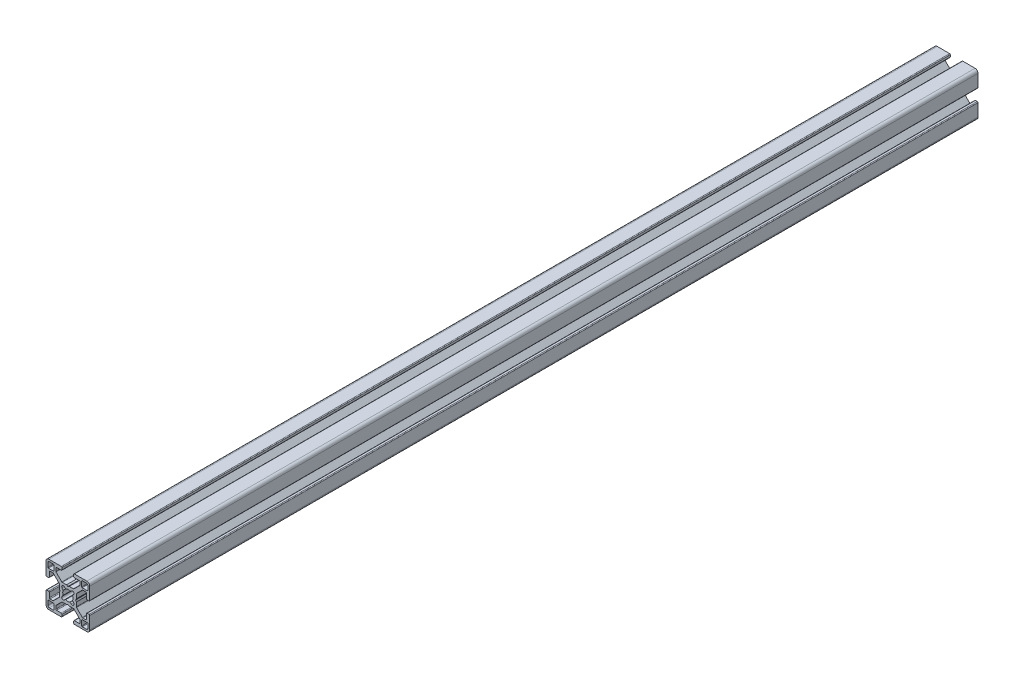
from build123d import *

# Parameters (mm, degrees)
EXTRUDE1_DEPTH = 609.6


with BuildPart() as part:
    # Sketch1 → Extrude1 (new body)
    with BuildSketch(Plane.XY):
        with BuildLine():
            Line((12.74247465, -4.5), (12.74247465, -7.732519321))
            ThreePointArc((12.74247465, -7.732519321), (12.602449697, -8.097296796), (12.242781236, -8.249967))
            Line((12.242781236, -8.249967), (10.260188032, -8.249967))
            ThreePointArc((10.260188032, -8.249967), (10.068847082, -8.211906919), (9.906636056, -8.103520976))
            Line((9.906636056, -8.103520976), (5.981117769, -4.178002689))
            ThreePointArc((5.981117769, -4.178002689), (5.872731827, -4.015791664), (5.834671745, -3.824450713))
            Line((5.834671745, -3.824450713), (5.834671745, -1.01249595))
            Line((5.834671745, -1.01249595), (5.324673785, -0.06249975))
            Line((5.324673785, -0.06249975), (5.834671745, 0.88749645))
            Line((5.834671745, 0.88749645), (5.834671745, 3.824450713))
            ThreePointArc((5.834671745, 3.824450713), (5.872731827, 4.015791664), (5.981117769, 4.178002689))
            Line((5.981117769, 4.178002689), (9.906636056, 8.103520976))
            ThreePointArc((9.906636056, 8.103520976), (10.068847082, 8.211906919), (10.260188032, 8.249967))
            Line((10.260188032, 8.249967), (12.242781236, 8.249967))
            ThreePointArc((12.242781236, 8.249967), (12.602449697, 8.097296796), (12.74247465, 7.732519321))
            Line((12.74247465, 7.732519321), (12.74247465, 4.5))
            ThreePointArc((12.74247465, 4.5), (12.88892126, 4.146446609), (13.24247465, 4))
            Line((13.24247465, 4), (14.49994, 4))
            ThreePointArc((14.49994, 4), (14.853493391, 4.146446609), (14.99994, 4.5))
            Line((14.99994, 4.5), (14.99994, 12.999948))
            ThreePointArc((14.99994, 12.999948), (14.414155906, 14.414155906), (12.999948, 14.99994))
            Line((12.999948, 14.99994), (4.5, 14.99994))
            ThreePointArc((4.5, 14.99994), (4.146446609, 14.853493391), (4, 14.49994))
            Line((4, 14.49994), (4, 13.24247465))
            ThreePointArc((4, 13.24247465), (4.146446609, 12.88892126), (4.5, 12.74247465))
            Line((4.5, 12.74247465), (7.732519321, 12.74247465))
            ThreePointArc((7.732519321, 12.74247465), (8.097296796, 12.602449697), (8.249967, 12.242781236))
            Line((8.249967, 12.242781236), (8.249967, 10.260188032))
            ThreePointArc((8.249967, 10.260188032), (8.211906919, 10.068847082), (8.103520976, 9.906636056))
            Line((8.103520976, 9.906636056), (4.178002689, 5.981117769))
            ThreePointArc((4.178002689, 5.981117769), (4.015791664, 5.872731827), (3.824450713, 5.834671745))
            Line((3.824450713, 5.834671745), (0.9499962, 5.834671745))
            Line((0.9499962, 5.834671745), (0, 5.324673785))
            Line((0, 5.324673785), (-0.9499962, 5.834671745))
            Line((-0.9499962, 5.834671745), (-3.824450713, 5.834671745))
            ThreePointArc((-3.824450713, 5.834671745), (-4.015791664, 5.872731827), (-4.178002689, 5.981117769))
            Line((-4.178002689, 5.981117769), (-8.103520976, 9.906636056))
            ThreePointArc((-8.103520976, 9.906636056), (-8.211906919, 10.068847082), (-8.249967, 10.260188032))
            Line((-8.249967, 10.260188032), (-8.249967, 12.242781236))
            ThreePointArc((-8.249967, 12.242781236), (-8.097296796, 12.602449697), (-7.732519321, 12.74247465))
            Line((-7.732519321, 12.74247465), (-4.5, 12.74247465))
            ThreePointArc((-4.5, 12.74247465), (-4.146446609, 12.88892126), (-4, 13.24247465))
            Line((-4, 13.24247465), (-4, 14.49994))
            ThreePointArc((-4, 14.49994), (-4.146446609, 14.853493391), (-4.5, 14.99994))
            Line((-4.5, 14.99994), (-12.999948, 14.99994))
            ThreePointArc((-12.999948, 14.99994), (-14.414155906, 14.414155906), (-14.99994, 12.999948))
            Line((-14.99994, 12.999948), (-14.99994, 4.5))
            ThreePointArc((-14.99994, 4.5), (-14.853493391, 4.146446609), (-14.49994, 4))
            Line((-14.49994, 4), (-13.24247465, 4))
            ThreePointArc((-13.24247465, 4), (-12.88892126, 4.146446609), (-12.74247465, 4.5))
            Line((-12.74247465, 4.5), (-12.74247465, 7.732519321))
            ThreePointArc((-12.74247465, 7.732519321), (-12.602449697, 8.097296796), (-12.242781236, 8.249967))
            Line((-12.242781236, 8.249967), (-10.260188032, 8.249967))
            ThreePointArc((-10.260188032, 8.249967), (-10.068847082, 8.211906919), (-9.906636056, 8.103520976))
            Line((-9.906636056, 8.103520976), (-5.981117769, 4.178002689))
            ThreePointArc((-5.981117769, 4.178002689), (-5.872731827, 4.015791664), (-5.834671745, 3.824450713))
            Line((-5.834671745, 3.824450713), (-5.834671745, 0.88749645))
            Line((-5.834671745, 0.88749645), (-5.324673785, -0.06249975))
            Line((-5.324673785, -0.06249975), (-5.834671745, -1.01249595))
            Line((-5.834671745, -1.01249595), (-5.834671745, -3.824450713))
            ThreePointArc((-5.834671745, -3.824450713), (-5.872731827, -4.015791664), (-5.981117769, -4.178002689))
            Line((-5.981117769, -4.178002689), (-9.906636056, -8.103520976))
            ThreePointArc((-9.906636056, -8.103520976), (-10.068847082, -8.211906919), (-10.260188032, -8.249967))
            Line((-10.260188032, -8.249967), (-12.242781236, -8.249967))
            ThreePointArc((-12.242781236, -8.249967), (-12.602449697, -8.097296796), (-12.74247465, -7.732519321))
            Line((-12.74247465, -7.732519321), (-12.74247465, -4.5))
            ThreePointArc((-12.74247465, -4.5), (-12.88892126, -4.146446609), (-13.24247465, -4))
            Line((-13.24247465, -4), (-14.49994, -4))
            ThreePointArc((-14.49994, -4), (-14.853493391, -4.146446609), (-14.99994, -4.5))
            Line((-14.99994, -4.5), (-14.99994, -12.999948))
            ThreePointArc((-14.99994, -12.999948), (-14.414155906, -14.414155906), (-12.999948, -14.99994))
            Line((-12.999948, -14.99994), (-4.5, -14.99994))
            ThreePointArc((-4.5, -14.99994), (-4.146446609, -14.853493391), (-4, -14.49994))
            Line((-4, -14.49994), (-4, -13.24247465))
            ThreePointArc((-4, -13.24247465), (-4.146446609, -12.88892126), (-4.5, -12.74247465))
            Line((-4.5, -12.74247465), (-7.732519321, -12.74247465))
            ThreePointArc((-7.732519321, -12.74247465), (-8.097296796, -12.602449697), (-8.249967, -12.242781236))
            Line((-8.249967, -12.242781236), (-8.249967, -10.260188032))
            ThreePointArc((-8.249967, -10.260188032), (-8.211906919, -10.068847082), (-8.103520976, -9.906636056))
            Line((-8.103520976, -9.906636056), (-4.178002689, -5.981117769))
            ThreePointArc((-4.178002689, -5.981117769), (-4.015791664, -5.872731827), (-3.824450713, -5.834671745))
            Line((-3.824450713, -5.834671745), (-0.9499962, -5.834671745))
            Line((-0.9499962, -5.834671745), (0, -5.324673785))
            Line((0, -5.324673785), (0.9499962, -5.834671745))
            Line((0.9499962, -5.834671745), (3.824450713, -5.834671745))
            ThreePointArc((3.824450713, -5.834671745), (4.015791664, -5.872731827), (4.178002689, -5.981117769))
            Line((4.178002689, -5.981117769), (8.103520976, -9.906636056))
            ThreePointArc((8.103520976, -9.906636056), (8.211906919, -10.068847082), (8.249967, -10.260188032))
            Line((8.249967, -10.260188032), (8.249967, -12.242781236))
            ThreePointArc((8.249967, -12.242781236), (8.097296796, -12.602449697), (7.732519321, -12.74247465))
            Line((7.732519321, -12.74247465), (4.5, -12.74247465))
            ThreePointArc((4.5, -12.74247465), (4.146446609, -12.88892126), (4, -13.24247465))
            Line((4, -13.24247465), (4, -14.49994))
            ThreePointArc((4, -14.49994), (4.146446609, -14.853493391), (4.5, -14.99994))
            Line((4.5, -14.99994), (12.999948, -14.99994))
            ThreePointArc((12.999948, -14.99994), (14.414155906, -14.414155906), (14.99994, -12.999948))
            Line((14.99994, -12.999948), (14.99994, -4.5))
            ThreePointArc((14.99994, -4.5), (14.853493391, -4.146446609), (14.49994, -4))
            Line((14.49994, -4), (13.24247465, -4))
            ThreePointArc((13.24247465, -4), (12.88892126, -4.146446609), (12.74247465, -4.5))
        make_face()
        with BuildLine():
            Line((9.499962, -13.318946724), (9.499962, -9.87996048))
            ThreePointArc((9.499962, -9.87996048), (9.611260978, -9.611260978), (9.87996048, -9.499962))
            Line((9.87996048, -9.499962), (13.318946724, -9.499962))
            ThreePointArc((13.318946724, -9.499962), (13.58835333, -9.61155387), (13.6999452, -9.880960476))
            Line((13.6999452, -9.880960476), (13.6999452, -12.6999492))
            ThreePointArc((13.6999452, -12.6999492), (13.407053153, -13.407053153), (12.6999492, -13.6999452))
            Line((12.6999492, -13.6999452), (9.880960476, -13.6999452))
            ThreePointArc((9.880960476, -13.6999452), (9.61155387, -13.58835333), (9.499962, -13.318946724))
        make_face(mode=Mode.SUBTRACT)
        with BuildLine():
            Line((-13.318946724, -9.499962), (-9.87996048, -9.499962))
            ThreePointArc((-9.87996048, -9.499962), (-9.611260978, -9.611260978), (-9.499962, -9.87996048))
            Line((-9.499962, -9.87996048), (-9.499962, -13.318946724))
            ThreePointArc((-9.499962, -13.318946724), (-9.61155387, -13.58835333), (-9.880960476, -13.6999452))
            Line((-9.880960476, -13.6999452), (-12.6999492, -13.6999452))
            ThreePointArc((-12.6999492, -13.6999452), (-13.407053153, -13.407053153), (-13.6999452, -12.6999492))
            Line((-13.6999452, -12.6999492), (-13.6999452, -9.880960476))
            ThreePointArc((-13.6999452, -9.880960476), (-13.58835333, -9.61155387), (-13.318946724, -9.499962))
        make_face(mode=Mode.SUBTRACT)
        with BuildLine():
            Line((-1.494225248, -3.198138712), (-2.473341823, -3.979927146))
            ThreePointArc((-2.473341823, -3.979927146), (-3.900227701, -3.900227701), (-3.979927146, -2.473341823))
            Line((-3.979927146, -2.473341823), (-3.198138712, -1.494225248))
            ThreePointArc((-3.198138712, -1.494225248), (-3.52998588, 0), (-3.198138712, 1.494225248))
            Line((-3.198138712, 1.494225248), (-3.979927146, 2.473341823))
            ThreePointArc((-3.979927146, 2.473341823), (-3.900227701, 3.900227701), (-2.473341823, 3.979927146))
            Line((-2.473341823, 3.979927146), (-1.494225248, 3.198138712))
            ThreePointArc((-1.494225248, 3.198138712), (0, 3.52998588), (1.494225248, 3.198138712))
            Line((1.494225248, 3.198138712), (2.473341823, 3.979927146))
            ThreePointArc((2.473341823, 3.979927146), (3.900227701, 3.900227701), (3.979927146, 2.473341823))
            Line((3.979927146, 2.473341823), (3.198138712, 1.494225248))
            ThreePointArc((3.198138712, 1.494225248), (3.52998588, 0), (3.198138712, -1.494225248))
            Line((3.198138712, -1.494225248), (3.979927146, -2.473341823))
            ThreePointArc((3.979927146, -2.473341823), (3.900227701, -3.900227701), (2.473341823, -3.979927146))
            Line((2.473341823, -3.979927146), (1.494225248, -3.198138712))
            ThreePointArc((1.494225248, -3.198138712), (0, -3.52998588), (-1.494225248, -3.198138712))
        make_face(mode=Mode.SUBTRACT)
        with BuildLine():
            Line((-9.499962, 13.318946724), (-9.499962, 9.87996048))
            ThreePointArc((-9.499962, 9.87996048), (-9.611260978, 9.611260978), (-9.87996048, 9.499962))
            Line((-9.87996048, 9.499962), (-13.318946724, 9.499962))
            ThreePointArc((-13.318946724, 9.499962), (-13.58835333, 9.61155387), (-13.6999452, 9.880960476))
            Line((-13.6999452, 9.880960476), (-13.6999452, 12.6999492))
            ThreePointArc((-13.6999452, 12.6999492), (-13.407053153, 13.407053153), (-12.6999492, 13.6999452))
            Line((-12.6999492, 13.6999452), (-9.880960476, 13.6999452))
            ThreePointArc((-9.880960476, 13.6999452), (-9.61155387, 13.58835333), (-9.499962, 13.318946724))
        make_face(mode=Mode.SUBTRACT)
        with BuildLine():
            Line((9.880960476, 13.6999452), (12.6999492, 13.6999452))
            ThreePointArc((12.6999492, 13.6999452), (13.407053153, 13.407053153), (13.6999452, 12.6999492))
            Line((13.6999452, 12.6999492), (13.6999452, 9.880960476))
            ThreePointArc((13.6999452, 9.880960476), (13.58835333, 9.61155387), (13.318946724, 9.499962))
            Line((13.318946724, 9.499962), (9.87996048, 9.499962))
            ThreePointArc((9.87996048, 9.499962), (9.611260978, 9.611260978), (9.499962, 9.87996048))
            Line((9.499962, 9.87996048), (9.499962, 13.318946724))
            ThreePointArc((9.499962, 13.318946724), (9.61155387, 13.58835333), (9.880960476, 13.6999452))
        make_face(mode=Mode.SUBTRACT)
    extrude(amount=-EXTRUDE1_DEPTH)


solid = part.part
